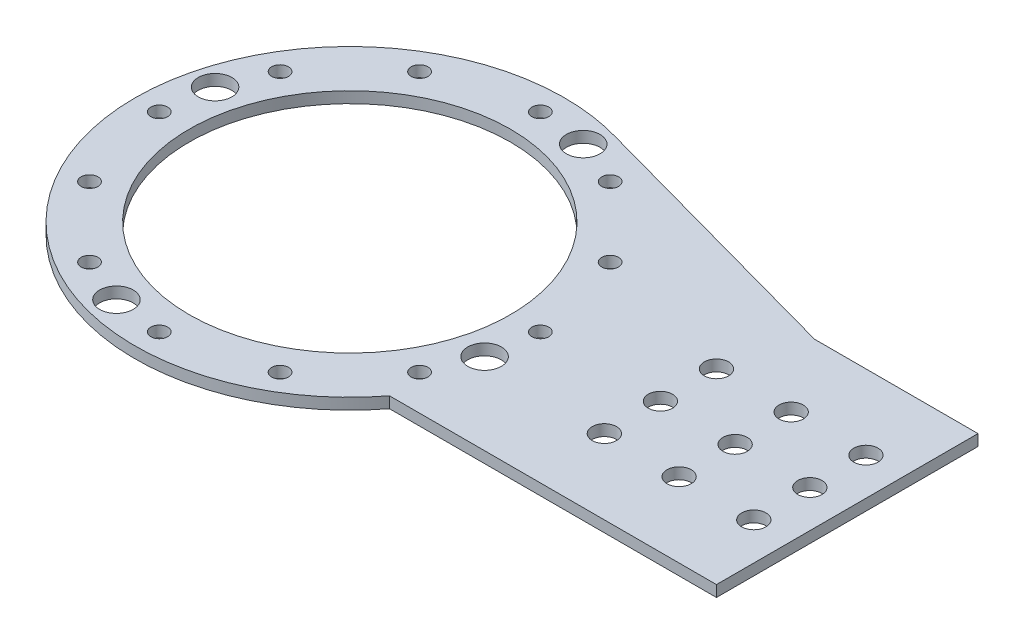
from build123d import *

# Parameters (mm, degrees)
SKETCH1_R           = 57.5
BOSS_EXTRUDE1_DEPTH = 3
SKETCH2_W           = 140
SKETCH2_H           = 70
BOSS_EXTRUDE2_DEPTH = 3
BOSS_EXTRUDE3_DEPTH = 3
SKETCH4_R           = 43
CUT_EXTRUDE1_DEPTH  = 4
SKETCH7_R           = 3.25
CUT_EXTRUDE8_DEPTH  = 4
LPATTERN1_COUNT     = 3
LPATTERN1_PITCH     = 20
CUT_EXTRUDE5_START  = -1
SKETCH5_R           = 2.25
CUT_EXTRUDE5_DEPTH  = 5
CIRPATTERN1_COUNT   = 12
SKETCH12_R          = 4.5
CUT_EXTRUDE17_DEPTH = 4
CIRPATTERN2_COUNT   = 4
SKETCH13_R          = 3.25
CUT_EXTRUDE18_DEPTH = 10
LPATTERN2_COUNT     = 3
LPATTERN2_PITCH     = 20


with BuildPart() as part:
    # Sketch1 → Boss-Extrude1 (new body)
    with BuildSketch(Plane(origin=(0, 0, 0), x_dir=(1, 0, 0), z_dir=(0, 1, 0))):
        Circle(SKETCH1_R)
    extrude(amount=BOSS_EXTRUDE1_DEPTH)

    # Sketch2 → Boss-Extrude2 (add)
    with BuildSketch(Plane(origin=(0, 0, 0), x_dir=(1, 0, 0), z_dir=(0, 1, 0))):
        with Locations((63.125798099, 0)):
            Rectangle(SKETCH2_W, SKETCH2_H)
    extrude(amount=BOSS_EXTRUDE2_DEPTH)

    # Sketch3 → Boss-Extrude3 (add)
    with BuildSketch(Plane(origin=(0, 0, 0), x_dir=(1, 0, 0), z_dir=(0, 1, 0))):
        Polygon((89.373258538, 35), (13.76852627, 55.827212758), (13.76852627, 13.558751548), align=None)
    extrude(amount=BOSS_EXTRUDE3_DEPTH)

    # Sketch4 → Cut-Extrude1 (cut, through all)
    with BuildSketch(Plane(origin=(0, 3, 0), x_dir=(1, 0, 0), z_dir=(0, 1, 0))):
        Circle(SKETCH4_R)
    extrude(amount=-CUT_EXTRUDE1_DEPTH, mode=Mode.SUBTRACT)

    # Sketch7 → Cut-Extrude8 (cut, through all)
    with BuildSketch(Plane(origin=(0, 3, 0), x_dir=(1, 0, 0), z_dir=(0, 1, 0))):
        with Locations((123.125798099, 15)):
            Circle(SKETCH7_R)
        with Locations((123.125798099, -15)):
            Circle(SKETCH7_R)
    cut_extrude8 = extrude(amount=-CUT_EXTRUDE8_DEPTH, mode=Mode.SUBTRACT)

    # LPattern1: Cut-Extrude8 ×3
    with Locations(*[(-i * LPATTERN1_PITCH, 0, 0) for i in range(1, LPATTERN1_COUNT)]):
        add(cut_extrude8, mode=Mode.SUBTRACT)

    # Sketch5 → Cut-Extrude5 (cut)
    with BuildSketch(Plane(origin=(0, 0, 0), x_dir=(1, 0, 0), z_dir=(0, 1, 0)).offset(CUT_EXTRUDE5_START)):
        with Locations((-51, 0)):
            Circle(SKETCH5_R)
    cut_extrude5 = extrude(amount=CUT_EXTRUDE5_DEPTH, mode=Mode.SUBTRACT)

    # CirPattern1: Cut-Extrude5 ×12 about axis
    cirpattern1_axis = Axis((0, 0, 0), (0, 1, 0))
    for i in range(1, CIRPATTERN1_COUNT):
        add(cut_extrude5.rotate(cirpattern1_axis, i * 360 / CIRPATTERN1_COUNT), mode=Mode.SUBTRACT)

    # Sketch12 → Cut-Extrude17 (cut, through all)
    with BuildSketch(Plane(origin=(0, 3, 0), x_dir=(1, 0, 0), z_dir=(0, 1, 0))):
        with Locations((-49.262217141, 13.1997713)):
            Circle(SKETCH12_R)
    cut_extrude17 = extrude(amount=-CUT_EXTRUDE17_DEPTH, mode=Mode.SUBTRACT)

    # CirPattern2: Cut-Extrude17 ×4 about axis
    cirpattern2_axis = Axis((0, 0, 0), (0, 1, 0))
    for i in range(1, CIRPATTERN2_COUNT):
        add(cut_extrude17.rotate(cirpattern2_axis, i * 360 / CIRPATTERN2_COUNT), mode=Mode.SUBTRACT)

    # Sketch13 → Cut-Extrude18 (cut)
    with BuildSketch(Plane(origin=(0, 3, 0), x_dir=(1, 0, 0), z_dir=(0, 1, 0))):
        with Locations((123.125798099, 0)):
            Circle(SKETCH13_R)
    cut_extrude18 = extrude(amount=-CUT_EXTRUDE18_DEPTH, mode=Mode.SUBTRACT)

    # LPattern2: Cut-Extrude18 ×3
    with Locations(*[(-i * LPATTERN2_PITCH, 0, 0) for i in range(1, LPATTERN2_COUNT)]):
        add(cut_extrude18, mode=Mode.SUBTRACT)


solid = part.part
